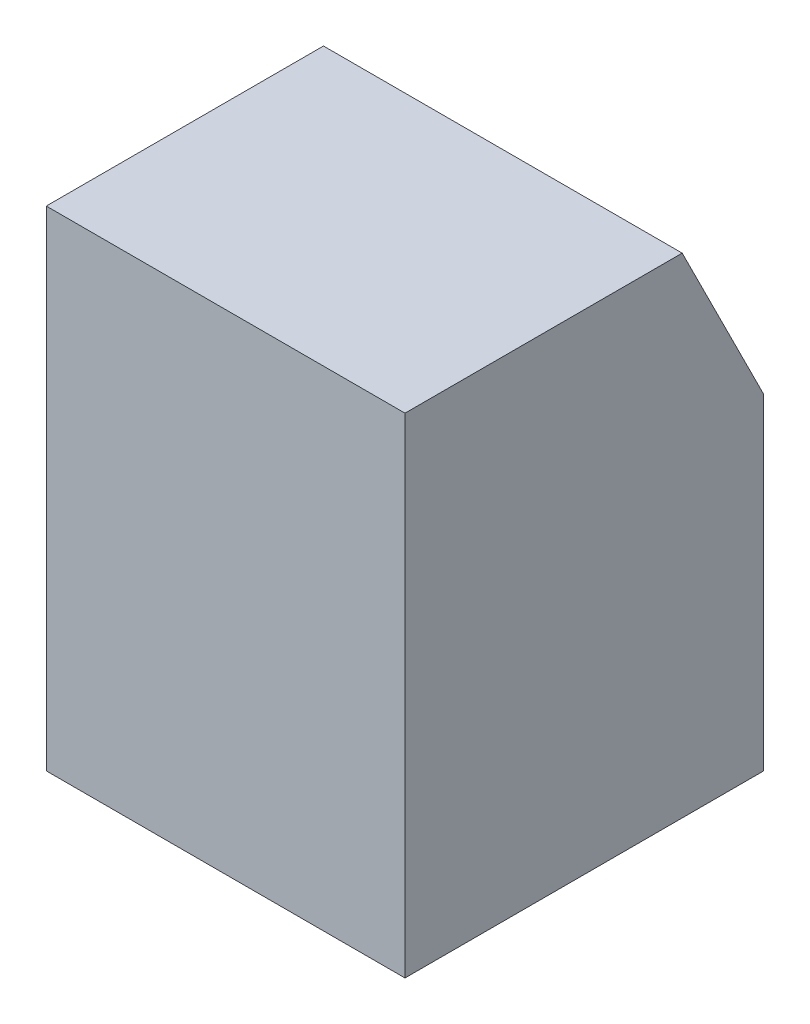
from build123d import *

# Parameters (mm, degrees)
BOSS_EXTRUDE1_DEPTH = 279.4
SKETCH2_R           = 12.7
CUT_EXTRUDE1_DEPTH  = 127


with BuildPart() as part:
    # Sketch1 → Boss-Extrude1 (new body)
    with BuildSketch(Plane(origin=(0, 0, 0), x_dir=(0, 0, -1), z_dir=(1, 0, 0))):
        Polygon((0, 0), (279.4, 0), (279.4, 254), (215.9, 381), (0, 381), align=None)
    extrude(amount=BOSS_EXTRUDE1_DEPTH)

    # Sketch2 → Cut-Extrude1 (cut)
    with BuildSketch(Plane(origin=(0, 0, -279.4), x_dir=(-1, 0, 0), z_dir=(0, 0, -1))):
        with Locations((-139.7, 165.1)):
            Circle(SKETCH2_R)
    extrude(amount=-CUT_EXTRUDE1_DEPTH, mode=Mode.SUBTRACT)


solid = part.part
